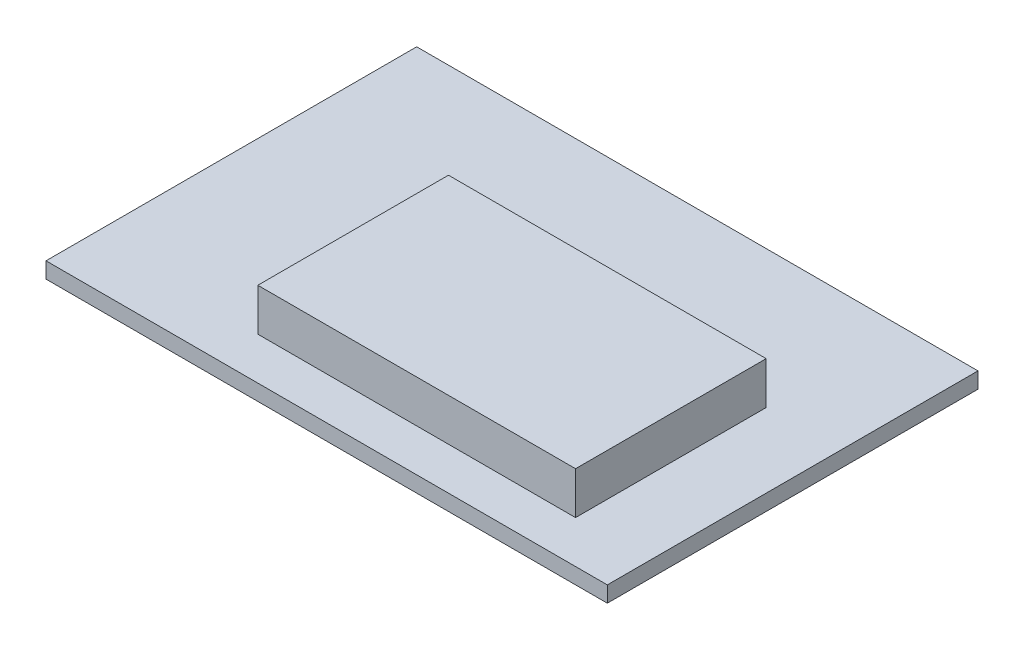
from build123d import *

# Parameters (mm, degrees)
ESBO_O1_W                = 53
ESBO_O1_H                = 35
RESSALTO_EXTRUS_O1_DEPTH = 1.5
ESBO_O2_W                = 30
ESBO_O2_H                = 18
RESSALTO_EXTRUS_O2_DEPTH = 4


with BuildPart() as part:
    # Esboço1 → Ressalto-extrusão1 (new body)
    with BuildSketch(Plane(origin=(0, 0, 0), x_dir=(1, 0, 0), z_dir=(0, 1, 0))):
        with Locations((-2.230622383, -1.974087289)):
            Rectangle(ESBO_O1_W, ESBO_O1_H)
    extrude(amount=RESSALTO_EXTRUS_O1_DEPTH)

    # Esboço2 → Ressalto-extrusão2 (add)
    with BuildSketch(Plane(origin=(0, 1.5, 0), x_dir=(1, 0, 0), z_dir=(0, 1, 0))):
        with Locations((2.269377617, -6.474087289)):
            Rectangle(ESBO_O2_W, ESBO_O2_H)
    extrude(amount=RESSALTO_EXTRUS_O2_DEPTH)


solid = part.part
